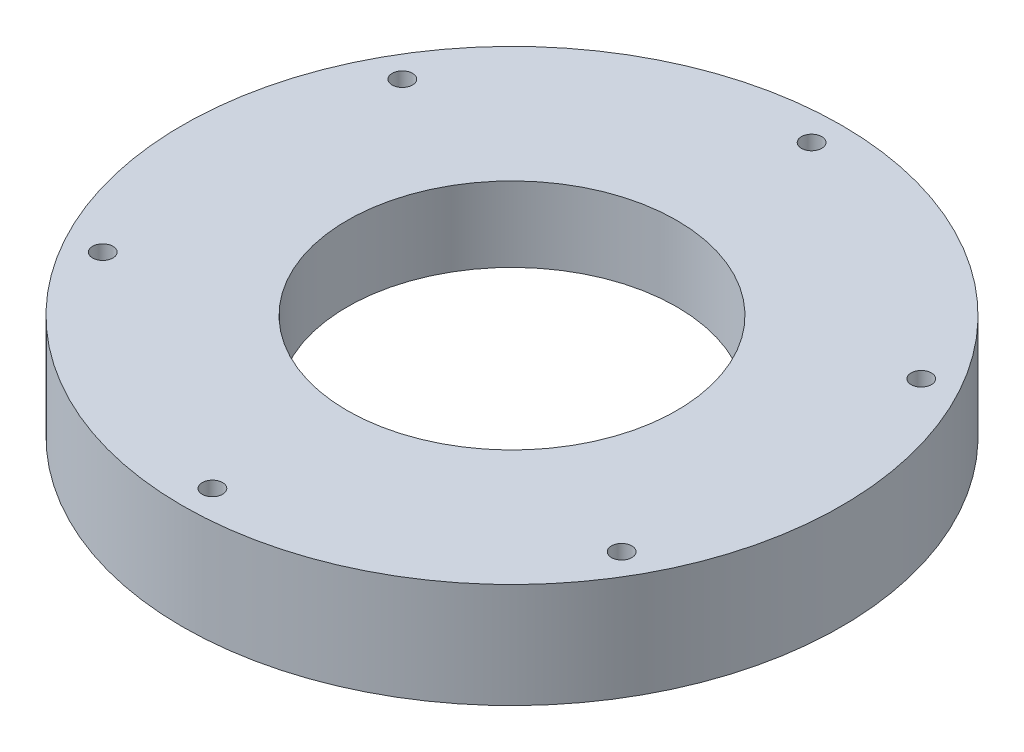
from build123d import *

# Parameters (mm, degrees)
SKETCH1_R           = 110
SKETCH1_R_2         = 55
SKETCH1_R_3         = 3.4
BOSS_EXTRUDE1_DEPTH = 35
SKETCH2_R           = 87.5
CUT_EXTRUDE1_DEPTH  = 10


with BuildPart() as part:
    # Sketch1 → Boss-Extrude1 (new body)
    with BuildSketch(Plane(origin=(0, 0, 0), x_dir=(1, 0, 0), z_dir=(0, 1, 0))):
        Circle(SKETCH1_R)
        Circle(SKETCH1_R_2, mode=Mode.SUBTRACT)
        with Locations((0, 100)):
            Circle(SKETCH1_R_3, mode=Mode.SUBTRACT)
        with Locations((86.602540378, 50)):
            Circle(SKETCH1_R_3, mode=Mode.SUBTRACT)
        with Locations((86.602540378, -50)):
            Circle(SKETCH1_R_3, mode=Mode.SUBTRACT)
        with Locations((0, -100)):
            Circle(SKETCH1_R_3, mode=Mode.SUBTRACT)
        with Locations((-86.602540378, -50)):
            Circle(SKETCH1_R_3, mode=Mode.SUBTRACT)
        with Locations((-86.602540378, 50)):
            Circle(SKETCH1_R_3, mode=Mode.SUBTRACT)
    extrude(amount=BOSS_EXTRUDE1_DEPTH)

    # Sketch2 → Cut-Extrude1 (cut)
    with BuildSketch(Plane.XZ):
        Circle(SKETCH2_R)
    extrude(amount=-CUT_EXTRUDE1_DEPTH, mode=Mode.SUBTRACT)


solid = part.part
